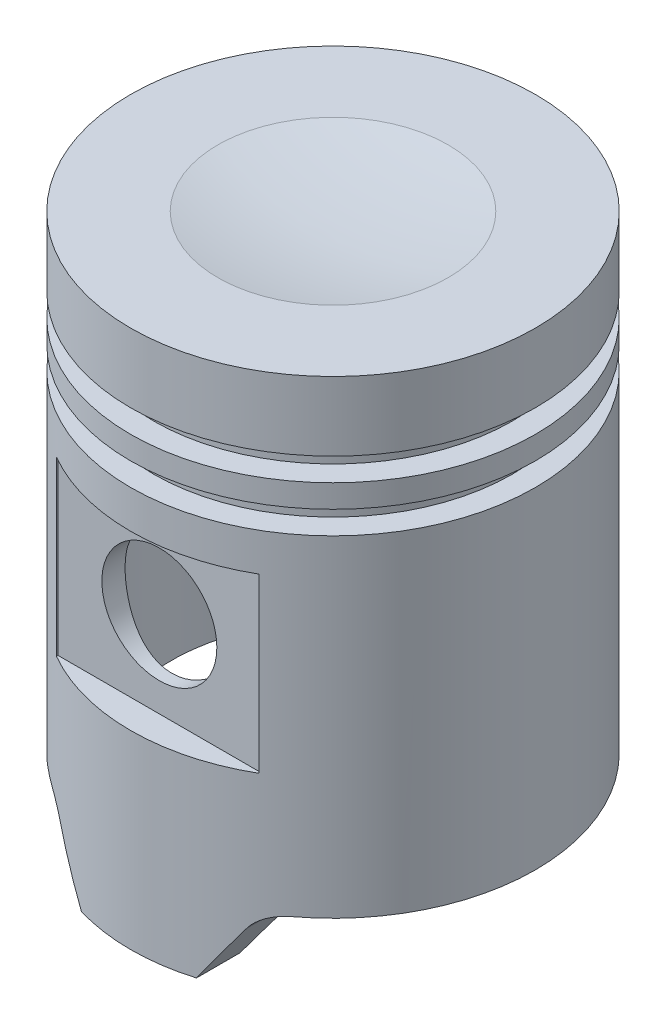
from build123d import *

# Parameters (mm, degrees)
SKETCH3_R               = 17.78
CUT_EXTRUDE2_DEPTH      = 51.816
SKETCH4_R               = 6.35
CUT_EXTRUDE3_DEPTH      = 23.352
CUT_EXTRUDE3_DEPTH_BACK = 23.352
CUT_EXTRUDE5_START      = 19.177
SKETCH5_W               = 22.352
SKETCH5_H               = 19.05
CUT_EXTRUDE5_DEPTH      = 4.1750001
CUT_EXTRUDE6_DEPTH      = 23.352


with BuildPart() as part:
    # Sketch1 → Revolve2 (revolve)
    with BuildSketch(Plane.XY):
        with BuildLine():
            Line((0, 0), (0, 58.166))
            ThreePointArc((0, 58.166), (6.387986381, 58.484288237), (12.712693656, 59.436))
            Line((12.712693656, 59.436), (22.352, 59.436))
            Line((22.352, 59.436), (22.352, 51.816))
            Line((22.352, 51.816), (19.812, 51.816))
            Line((19.812, 51.816), (19.812, 49.276))
            Line((19.812, 49.276), (22.352, 49.276))
            Line((22.352, 49.276), (22.352, 46.736))
            Line((22.352, 46.736), (19.812, 46.736))
            Line((19.812, 46.736), (19.812, 44.196))
            Line((19.812, 44.196), (22.352, 44.196))
            Line((22.352, 44.196), (22.352, 0))
            Line((22.352, 0), (0, 0))
        make_face()
    revolve(axis=Axis((0, 0, 0), (0, 1, 0)))

    # Sketch3 → Cut-Extrude2 (cut)
    with BuildSketch(Plane(origin=(0, 0, 0), x_dir=(-1, 0, 0), z_dir=(0, -1, 0))):
        Circle(SKETCH3_R)
    extrude(amount=-CUT_EXTRUDE2_DEPTH, mode=Mode.SUBTRACT)

    # Sketch4 → Cut-Extrude3 (cut, two sides)
    with BuildSketch(Plane.XY) as cut_extrude3_sk:
        with Locations((0, 30.48)):
            Circle(SKETCH4_R)
    extrude(amount=CUT_EXTRUDE3_DEPTH, mode=Mode.SUBTRACT)
    extrude(cut_extrude3_sk.sketch, amount=-CUT_EXTRUDE3_DEPTH_BACK, mode=Mode.SUBTRACT)

    # Sketch5 → Cut-Extrude5 (cut, through all)
    with BuildSketch(Plane.XY.offset(CUT_EXTRUDE5_START)):
        with Locations((0, 30.48)):
            Rectangle(SKETCH5_W, SKETCH5_H)
    cut_extrude5 = extrude(amount=CUT_EXTRUDE5_DEPTH, mode=Mode.SUBTRACT)

    # Mirror1: Cut-Extrude5 across plane
    add(cut_extrude5.mirror(Plane.XY), mode=Mode.SUBTRACT)

    # Sketch6 → Cut-Extrude6 (cut, symmetric)
    with BuildSketch(Plane.XY):
        with BuildLine():
            Line((22.352, 7.62), (13.470533586, 7.62))
            ThreePointArc((13.470533586, 7.62), (11.673046061, 7.169336035), (10.300788381, 5.923957269))
            Line((10.300788381, 5.923957269), (6.35, 0))
            Line((6.35, 0), (22.352, 0))
            Line((22.352, 0), (22.352, 7.62))
        make_face()
    cut_extrude6 = extrude(amount=CUT_EXTRUDE6_DEPTH, both=True, mode=Mode.SUBTRACT)

    # Mirror2: Cut-Extrude6 across plane
    add(cut_extrude6.mirror(Plane(origin=(0, 0, 0), x_dir=(0, 0, 1), z_dir=(1, 0, 0))), mode=Mode.SUBTRACT)


solid = part.part
